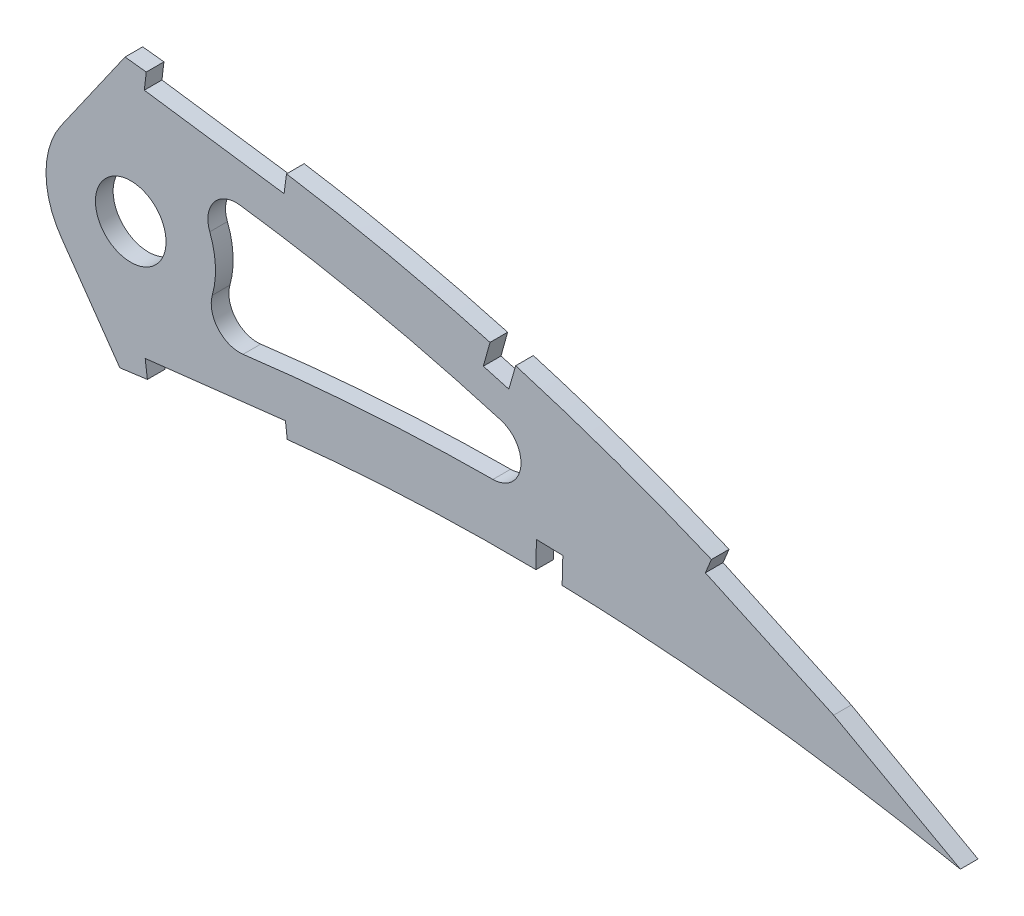
from build123d import *

# Parameters (mm, degrees)
BOSS_EXTRUDE1_DEPTH     = 3.175
SKETCH3_R               = 6.35
CUT_EXTRUDE2_DEPTH      = 7.62
CUT_EXTRUDE3_DEPTH      = 460.680430564
CUT_EXTRUDE3_DEPTH_BACK = 460.680430564
CUT_EXTRUDE4_DEPTH      = 459.987889409
FILLET1_R               = 5.08


with BuildPart() as part:
    # Sketch1 → Boss-Extrude1 (new body)
    with BuildSketch(Plane.XY):
        with BuildLine():
            Line((452.103130844, 0.704841059), (456.093968789, -1.676407199))
            Line((456.093968789, -1.676407199), (451.539257956, -0.704841059))
            add(Edge.make_bspline(
                [(0, 0), (0.116098484, -0.548062271), (0.348829019, -1.646705608), (0.981127511, -3.228296827), (1.817312083, -4.748664111), (2.874932324, -6.203769023), (4.146956076, -7.593213852), (5.630573928, -8.918443806), (7.324330898, -10.17874635), (9.226010202, -11.373547856), (11.332849305, -12.504116729), (13.642480166, -13.569749989), (16.152796843, -14.570114683), (18.861064307, -15.503873502), (21.763971588, -16.372448625), (24.858758771, -17.173723352), (28.141906776, -17.908817596), (31.610257831, -18.575854993), (35.260032504, -19.175513209), (39.087439203, -19.707456616), (43.088549366, -20.172017908), (47.259437594, -20.568222339), (51.595978462, -20.896922095), (56.093849686, -21.158335191), (60.748685259, -21.353290574), (65.556026339, -21.481047186), (70.511164689, -21.543596642), (75.60962225, -21.541878079), (80.846411515, -21.475431763), (86.217059019, -21.347928406), (91.716411041, -21.158560481), (97.339502767, -20.909619435), (103.081262098, -20.60361064), (108.936539298, -20.241571378), (114.900181528, -19.825106256), (120.967010704, -19.35755507), (127.131515672, -18.84008407), (133.388320155, -18.27570942), (139.73188498, -17.667256592), (146.156729407, -17.016651105), (152.657182369, -16.326953548), (159.227454029, -15.600398833), (165.861955098, -14.840863119), (172.554624992, -14.049720613), (179.299804335, -13.231488425), (186.0911476, -12.387729793), (192.922975871, -11.521694689), (199.789144556, -10.637460813), (206.683225759, -9.734927313), (213.599421065, -8.820524357), (220.53106073, -7.893498895), (227.472111233, -6.958618548), (234.416147314, -6.018789286), (241.356405409, -5.07430035), (248.28678484, -4.129065861), (255.200856388, -3.185680808), (262.091847615, -2.244231265), (268.953524037, -1.309396646), (275.778976202, -0.38106275), (282.561910312, 0.538888344), (289.295826346, 1.447710664), (295.974371147, 2.344257157), (302.590655451, 3.227960607), (309.138022785, 4.099152889), (315.511866205, 4.931391047), (321.69553077, 5.768992271), (327.709854245, 6.4556395), (333.649291775, 7.04171769), (339.520012945, 7.522220911), (345.31496828, 7.904062197), (351.027518107, 8.189969928), (356.650854245, 8.383935735), (362.17787359, 8.491713952), (367.601672755, 8.516039607), (372.914848341, 8.464670411), (378.110490176, 8.34174704), (383.181346836, 8.152787103), (388.120344083, 7.904165623), (392.920466429, 7.60266025), (397.574507523, 7.252718477), (402.075982121, 6.8625098), (406.417945063, 6.437746476), (410.593729281, 5.983281443), (414.597241701, 5.508637621), (418.422074216, 5.016940024), (422.062473684, 4.516268978), (425.512580015, 4.011698392), (428.766929364, 3.509669922), (431.820408455, 3.014973074), (434.668085107, 2.534173613), (437.305498365, 2.071763811), (439.728071725, 1.632259415), (441.932444373, 1.221205742), (443.914262697, 0.840644737), (445.670876088, 0.49684807), (447.199018295, 0.19133282), (448.496449148, -0.071596745), (449.560902928, -0.290902855), (450.390762879, -0.462985534), (450.984389878, -0.5881196), (451.34114184, -0.662580877), (451.499651332, -0.696392563), (451.539257956, -0.704841059)],
                knots=[0, 0, 0, 0, 0.003638255, 0.007293231, 0.011028136, 0.014901081, 0.018963272, 0.023258475, 0.027820626, 0.032679082, 0.03785316, 0.043361875, 0.049214679, 0.055422346, 0.061988786, 0.068918036, 0.076211157, 0.083868392, 0.091887411, 0.100265912, 0.108999867, 0.118084529, 0.127514843, 0.13728527, 0.147387917, 0.157816481, 0.168563473, 0.179619128, 0.190977373, 0.202626974, 0.214560478, 0.226767249, 0.239236417, 0.251959004, 0.264923894, 0.278119703, 0.291536035, 0.30516028, 0.318980685, 0.332985499, 0.34716279, 0.361498603, 0.375980747, 0.390597192, 0.405332593, 0.420174823, 0.435109533, 0.450124276, 0.465203068, 0.480333154, 0.495500583, 0.510689775, 0.525887334, 0.541078314, 0.556247233, 0.571381785, 0.58646604, 0.601484515, 0.616424329, 0.631269423, 0.646006524, 0.660620684, 0.675098187, 0.689422858, 0.703581825, 0.716907563, 0.730009274, 0.742952128, 0.755725557, 0.768319951, 0.780724337, 0.792926528, 0.804916041, 0.816679084, 0.828203525, 0.8394749, 0.850481359, 0.861207697, 0.871639326, 0.881763414, 0.891563605, 0.901027365, 0.910138977, 0.918883977, 0.927249278, 0.935221104, 0.942784739, 0.949928188, 0.956638465, 0.962904203, 0.968712288, 0.974054485, 0.978918432, 0.983297219, 0.987180246, 0.990560674, 0.993433357, 0.995790626, 0.997629588, 0.998945816, 0.999736592, 1, 1, 1, 1], degree=3))
            add(Edge.make_bspline(
                [(452.103130844, 0.704841059), (452.068496813, 0.726236426), (451.930095213, 0.811734792), (451.618251437, 1.003015711), (451.098966561, 1.321603382), (450.372013154, 1.765285304), (449.437955605, 2.332883088), (448.296324058, 3.020422222), (446.947831268, 3.825669225), (445.392803438, 4.744815234), (443.631400049, 5.773556989), (441.66429165, 6.907726386), (439.491649667, 8.140902925), (437.114315549, 9.468047233), (434.533105048, 10.882848063), (431.748506266, 12.378914822), (428.761516485, 13.948638114), (425.573282246, 15.58526602), (422.184384898, 17.279761053), (418.59642206, 19.025070833), (414.810589229, 20.812493246), (410.828178709, 22.632492429), (406.65147817, 24.477648573), (402.281642423, 26.336490908), (397.721161703, 28.200965635), (392.971977542, 30.06046153), (388.036901986, 31.906510246), (382.917838926, 33.727152381), (377.618614974, 35.514431666), (372.141800823, 37.256737501), (366.491313143, 38.944607324), (360.670434952, 40.56709799), (354.684018662, 42.115888344), (348.535860801, 43.579699531), (342.231172339, 44.948733274), (335.774964791, 46.214747245), (329.172652762, 47.36510198), (322.442531978, 48.398900537), (315.692888447, 49.25884604), (308.957131835, 50.102255317), (302.231406377, 50.894561333), (295.423478513, 51.653303868), (288.539897863, 52.374211064), (281.587492313, 53.055028822), (274.573300246, 53.692818583), (267.504610588, 54.285710178), (260.388263375, 54.830343915), (253.231762389, 55.325880728), (246.04218283, 55.767964282), (238.827182474, 56.156262652), (231.594085468, 56.488067665), (224.350419046, 56.761093174), (217.103874943, 56.973690929), (209.861975326, 57.123824182), (202.632561324, 57.210549036), (195.423152651, 57.231495803), (188.241586793, 57.186289729), (181.095384018, 57.073378669), (173.992389816, 56.89121691), (166.940134698, 56.63946441), (159.9462446, 56.318230463), (153.018377106, 55.924824851), (146.164047723, 55.461754745), (139.39088931, 54.92707481), (132.706343647, 54.320642895), (126.117416199, 53.644986873), (119.631442696, 52.898268934), (113.255374135, 52.082613865), (106.996184656, 51.199620764), (100.86089724, 50.248808671), (94.856084142, 49.232924024), (88.98822628, 48.153006108), (83.263531815, 47.012221039), (77.688233433, 45.810866329), (72.268232878, 44.552545746), (67.009162956, 43.23945158), (61.916677035, 41.873987713), (56.99593741, 40.459430694), (52.251920045, 38.998989643), (47.690155321, 37.494269359), (43.314090924, 35.950975056), (39.129102409, 34.370202293), (35.138395613, 32.756820932), (31.346647327, 31.113033952), (27.756690145, 29.443852436), (24.372587071, 27.751176724), (21.196749975, 26.039749097), (18.232367129, 24.312193837), (15.482292083, 22.571719722), (12.9476807, 20.82274152), (10.632027491, 19.066357057), (8.536127933, 17.307004609), (6.661308341, 15.547363257), (5.010248609, 13.788645116), (3.582889331, 12.033947283), (2.381101114, 10.284659424), (1.405092396, 8.542436815), (0.657070826, 6.808544998), (0.13629461, 5.083959089), (-0.148774805, 3.371224525), (-0.21973029, 1.668968236), (-0.073133992, 0.555491501), (0, 0)],
                knots=[0, 0, 0, 0, 0.00025409, 0.001015373, 0.002283359, 0.004056577, 0.006330982, 0.009105274, 0.012374489, 0.016134023, 0.02037966, 0.025105976, 0.030306237, 0.035972206, 0.042099522, 0.048678064, 0.055701664, 0.063160184, 0.071045824, 0.079349826, 0.08806291, 0.097175756, 0.106678112, 0.116561573, 0.126814275, 0.137428301, 0.148393618, 0.15969976, 0.171338126, 0.183297699, 0.195569604, 0.208143556, 0.221011593, 0.234161831, 0.24758745, 0.261276822, 0.27522271, 0.289414144, 0.303771199, 0.317689227, 0.331784111, 0.346039677, 0.36044387, 0.37498272, 0.389640454, 0.404403316, 0.419256601, 0.434186749, 0.449177265, 0.464214782, 0.479284009, 0.49436974, 0.509457833, 0.524532346, 0.53957932, 0.554582984, 0.569529546, 0.584403417, 0.599190992, 0.613876838, 0.628447475, 0.642888675, 0.657186054, 0.671325546, 0.685294014, 0.699078147, 0.712665095, 0.726042645, 0.739197713, 0.752117586, 0.764792042, 0.777208152, 0.789355685, 0.80122396, 0.812803686, 0.824082909, 0.835054602, 0.845709571, 0.856037853, 0.866033834, 0.875688843, 0.884997719, 0.893953426, 0.902552897, 0.910789386, 0.918660734, 0.926166253, 0.933302626, 0.94007122, 0.94647478, 0.952517526, 0.958204819, 0.963546652, 0.9685566, 0.973249913, 0.977651041, 0.981787043, 0.985694226, 0.989415109, 0.993001157, 0.996508416, 1, 1, 1, 1], degree=3))
        make_face()
    extrude(amount=BOSS_EXTRUDE1_DEPTH)

    # Sketch3 → Cut-Extrude2 (cut)
    with BuildSketch(Plane(origin=(0, 0, 0), x_dir=(-1, 0, 0), z_dir=(0, 0, -1))):
        with Locations((-299.038447077, 26.255421435)):
            Circle(SKETCH3_R)
    extrude(amount=-CUT_EXTRUDE2_DEPTH, mode=Mode.SUBTRACT)

    # Sketch4 → Cut-Extrude3 (cut, two sides)
    with BuildSketch(Plane.XY.offset(3.175)) as cut_extrude3_sk:
        with BuildLine():
            ThreePointArc((286.554569922, 17.514116545), (283.798447077, 26.255421435), (286.554569922, 34.996726325))
            Line((286.554569922, 34.996726325), (291.360999499, 41.861019145))
            Line((291.360999499, 41.861019145), (298.013920258, 51.362374666))
            add(Edge.make_bspline(
                [(298.013920258, 51.362374666), (297.158172729, 51.45702442), (294.008181803, 51.801525794), (288.539897863, 52.374211064), (281.587492313, 53.055028822), (274.573300246, 53.692818583), (267.504610588, 54.285710178), (260.388263375, 54.830343915), (253.231762389, 55.325880728), (246.04218283, 55.767964282), (238.827182474, 56.156262652), (231.594085468, 56.488067665), (224.350419046, 56.761093174), (217.103874943, 56.973690929), (209.861975326, 57.123824182), (202.632561324, 57.210549036), (195.423152651, 57.231495803), (188.241586793, 57.186289729), (181.095384018, 57.073378669), (173.992389816, 56.89121691), (166.940134698, 56.63946441), (159.9462446, 56.318230463), (154.912407449, 56.032379184), (152.210390737, 55.861831716), (151.817548324, 55.836670076)],
                knots=[0.340665949, 0.340665949, 0.340665949, 0.340665949, 0.346039677, 0.36044387, 0.37498272, 0.389640454, 0.404403316, 0.419256601, 0.434186749, 0.449177265, 0.464214782, 0.479284009, 0.49436974, 0.509457833, 0.524532346, 0.53957932, 0.554582984, 0.569529546, 0.584403417, 0.599190992, 0.613876838, 0.628447475, 0.642888675, 0.645345618, 0.645345618, 0.645345618, 0.645345618], degree=3))
            add(Edge.make_bspline(
                [(151.817548324, 55.836670076), (149.924372746, 55.715411774), (145.771614423, 55.430775666), (139.39088931, 54.92707481), (132.706343647, 54.320642895), (126.117416199, 53.644986873), (119.631442696, 52.898268934), (113.255374135, 52.082613865), (106.996184656, 51.199620764), (100.86089724, 50.248808671), (94.856084142, 49.232924024), (88.98822628, 48.153006108), (83.263531815, 47.012221039), (77.688233433, 45.810866329), (72.268232878, 44.552545746), (67.009162956, 43.23945158), (61.916677035, 41.873987713), (56.99593741, 40.459430694), (52.251920045, 38.998989643), (47.690155321, 37.494269359), (43.314090924, 35.950975056), (39.129102409, 34.370202293), (35.138395613, 32.756820932), (31.346647327, 31.113033952), (27.756690145, 29.443852436), (24.372587071, 27.751176724), (21.196749975, 26.039749097), (18.232367129, 24.312193837), (15.482292083, 22.571719722), (12.9476807, 20.82274152), (10.632027491, 19.066357057), (8.536127933, 17.307004609), (6.661308341, 15.547363257), (5.010248609, 13.788645116), (3.582889331, 12.033947283), (2.381101114, 10.284659424), (1.405092396, 8.542436815), (0.657070826, 6.808544998), (0.13629461, 5.083959089), (-0.148774805, 3.371224525), (-0.21973029, 1.668968236), (-0.073133992, 0.555491501), (0, 0)],
                knots=[0.645345618, 0.645345618, 0.645345618, 0.645345618, 0.657186054, 0.671325546, 0.685294014, 0.699078147, 0.712665095, 0.726042645, 0.739197713, 0.752117586, 0.764792042, 0.777208152, 0.789355685, 0.80122396, 0.812803686, 0.824082909, 0.835054602, 0.845709571, 0.856037853, 0.866033834, 0.875688843, 0.884997719, 0.893953426, 0.902552897, 0.910789386, 0.918660734, 0.926166253, 0.933302626, 0.94007122, 0.94647478, 0.952517526, 0.958204819, 0.963546652, 0.9685566, 0.973249913, 0.977651041, 0.981787043, 0.985694226, 0.989415109, 0.993001157, 0.996508416, 1, 1, 1, 1], degree=3))
            add(Edge.make_bspline(
                [(0, 0), (0.116098484, -0.548062271), (0.348829019, -1.646705608), (0.981127511, -3.228296827), (1.817312083, -4.748664111), (2.874932324, -6.203769023), (4.146956076, -7.593213852), (5.630573928, -8.918443806), (7.324330898, -10.17874635), (9.226010202, -11.373547856), (11.332849305, -12.504116729), (13.642480166, -13.569749989), (16.152796843, -14.570114683), (18.861064307, -15.503873502), (21.763971588, -16.372448625), (24.858758771, -17.173723352), (28.141906776, -17.908817596), (31.610257831, -18.575854993), (35.260032504, -19.175513209), (39.087439203, -19.707456616), (43.088549366, -20.172017908), (47.259437594, -20.568222339), (51.595978462, -20.896922095), (56.093849686, -21.158335191), (60.748685259, -21.353290574), (65.556026339, -21.481047186), (70.511164689, -21.543596642), (75.60962225, -21.541878079), (80.846411515, -21.475431763), (86.217059019, -21.347928406), (91.716411041, -21.158560481), (97.339502767, -20.909619435), (103.081262098, -20.60361064), (108.936539298, -20.241571378), (114.900181528, -19.825106256), (120.967010704, -19.35755507), (127.131515672, -18.84008407), (133.388320155, -18.27570942), (139.73188498, -17.667256592), (146.156729407, -17.016651105), (152.657182369, -16.326953548), (159.227454029, -15.600398833), (164.423185784, -15.00557734), (167.428285856, -14.653970639), (168.221856304, -14.560625117)],
                knots=[0, 0, 0, 0, 0.003638255, 0.007293231, 0.011028136, 0.014901081, 0.018963272, 0.023258475, 0.027820626, 0.032679082, 0.03785316, 0.043361875, 0.049214679, 0.055422346, 0.061988786, 0.068918036, 0.076211157, 0.083868392, 0.091887411, 0.100265912, 0.108999867, 0.118084529, 0.127514843, 0.13728527, 0.147387917, 0.157816481, 0.168563473, 0.179619128, 0.190977373, 0.202626974, 0.214560478, 0.226767249, 0.239236417, 0.251959004, 0.264923894, 0.278119703, 0.291536035, 0.30516028, 0.318980685, 0.332985499, 0.34716279, 0.361498603, 0.375980747, 0.381177933, 0.381177933, 0.381177933, 0.381177933], degree=3))
            add(Edge.make_bspline(
                [(168.221856304, -14.560625117), (169.660104846, -14.391447873), (173.347852421, -13.953497195), (179.299804335, -13.231488425), (186.0911476, -12.387729793), (192.922975871, -11.521694689), (199.789144556, -10.637460813), (206.683225759, -9.734927313), (213.599421065, -8.820524357), (220.53106073, -7.893498895), (227.472111233, -6.958618548), (234.416147314, -6.018789286), (241.356405409, -5.07430035), (248.28678484, -4.129065861), (255.200856388, -3.185680808), (262.091847615, -2.244231265), (268.953524037, -1.309396646), (275.778976202, -0.38106275), (282.561910312, 0.538888344), (289.295826346, 1.447710664), (294.127893032, 2.096380782), (296.714481339, 2.44258854), (297.074078933, 2.490700718)],
                knots=[0.381177933, 0.381177933, 0.381177933, 0.381177933, 0.390597192, 0.405332593, 0.420174823, 0.435109533, 0.450124276, 0.465203068, 0.480333154, 0.495500583, 0.510689775, 0.525887334, 0.541078314, 0.556247233, 0.571381785, 0.58646604, 0.601484515, 0.616424329, 0.631269423, 0.646006524, 0.660620684, 0.662980449, 0.662980449, 0.662980449, 0.662980449], degree=3))
            Line((297.074078933, 2.490700718), (290.512280083, 11.861920667))
            Line((290.512280083, 11.861920667), (286.554569922, 17.514116545))
        make_face()
        with BuildLine():
            add(Edge.make_bspline(
                [(397.099522024, 17.473424975), (391.104870759, 19.944342333), (379.177241568, 24.454975752), (361.031599335, 30.108120681), (345.827122006, 33.867334113), (333.567983327, 36.314328103), (325.822177912, 37.620830237), (319.688308692, 38.50590344), (314.963719571, 39.109215878), (310.159271505, 39.713456799), (306.795732769, 40.122713606), (305.012513563, 40.334581661), (304.815814132, 40.357890364)],
                knots=[0.119621685, 0.119621685, 0.119621685, 0.119621685, 0.161336405, 0.201670506, 0.242004607, 0.262171657, 0.282338708, 0.292422233, 0.302505759, 0.312589284, 0.322672809, 0.323922714, 0.323922714, 0.323922714, 0.323922714], degree=3))
            ThreePointArc((304.815814132, 40.357890364), (311.693577932, 34.746903228), (314.278447077, 26.255421435))
            ThreePointArc((314.278447077, 26.255421435), (312.737622507, 19.577832608), (308.426715772, 14.250505321))
            add(Edge.make_bspline(
                [(308.426715772, 14.250505321), (309.883764278, 14.442106028), (312.813862177, 14.824905538), (317.172571012, 15.411601995), (321.750889037, 16.002865885), (327.831130307, 16.688761643), (335.429886376, 17.415497246), (347.62570179, 18.27521734), (362.899139077, 18.793639217), (380.425060388, 18.544010551), (391.813646799, 17.883889315), (397.099522024, 17.473424975)],
                knots=[0.690710776, 0.690710776, 0.690710776, 0.690710776, 0.700258061, 0.709927156, 0.719596251, 0.729265346, 0.748603535, 0.767941725, 0.806618104, 0.845294483, 0.878913441, 0.878913441, 0.878913441, 0.878913441], degree=3))
        make_face()
    extrude(amount=CUT_EXTRUDE3_DEPTH, mode=Mode.SUBTRACT)
    extrude(cut_extrude3_sk.sketch, amount=-CUT_EXTRUDE3_DEPTH_BACK, mode=Mode.SUBTRACT)

    # Sketch5 → Cut-Extrude4 (cut, through all)
    with BuildSketch(Plane.XY.offset(3.175)):
        with BuildLine():
            add(Edge.make_bspline(
                [(307.959300125, 50.214688749), (306.058923831, 50.443506309), (304.01571842, 50.683216606), (301.971854133, 50.917122235), (301.829686497, 50.933363768)],
                knots=[0.319837191, 0.319837191, 0.319837191, 0.319837191, 0.331784111, 0.332677221, 0.332677221, 0.332677221, 0.332677221], degree=3))
            Line((301.829686497, 50.933363768), (301.47482345, 47.924910023))
            Line((301.47482345, 47.924910023), (326.610444398, 44.375507873))
            Line((326.610444398, 44.375507873), (327.027010314, 47.522970534))
            Line((327.027010314, 47.522970534), (307.959300125, 50.214688749))
        make_face()
        with BuildLine():
            add(Edge.make_bspline(
                [(327.049592603, 47.682939934), (325.523118102, 47.922682111), (321.719757816, 48.490986347), (315.692888447, 49.25884604), (310.85639105, 49.864441967), (308.300973051, 50.173549126), (307.959300125, 50.214688749)],
                knots=[0.279770165, 0.279770165, 0.279770165, 0.279770165, 0.289414144, 0.303771199, 0.317689227, 0.319837191, 0.319837191, 0.319837191, 0.319837191], degree=3))
            Line((307.959300125, 50.214688749), (327.027010314, 47.522970534))
            Line((327.027010314, 47.522970534), (327.049592603, 47.682939934))
        make_face()
        with BuildLine():
            Line((367.027712556, 34.144621107), (368.258765586, 38.409847596))
            add(Edge.make_bspline(
                [(368.258765586, 38.409847596), (367.683881505, 38.57934129), (366.146716026, 39.027931219), (364.606254541, 39.465110892), (363.641136877, 39.734202803)],
                knots=[0.191828805, 0.191828805, 0.191828805, 0.191828805, 0.195569604, 0.201823073, 0.201823073, 0.201823073, 0.201823073], degree=3))
            Line((363.641136877, 39.734202803), (362.440286106, 35.422164031))
            Line((362.440286106, 35.422164031), (367.027712556, 34.144621107))
        make_face()
        with BuildLine():
            add(Edge.make_bspline(
                [(368.258765586, 38.409847596), (367.683881505, 38.57934129), (366.146716026, 39.027931219), (364.606254541, 39.465110892), (363.641136877, 39.734202803)],
                knots=[0.191828805, 0.191828805, 0.191828805, 0.191828805, 0.195569604, 0.201823073, 0.201823073, 0.201823073, 0.201823073], degree=3))
            Line((368.258765586, 38.409847596), (368.338561592, 38.686316626))
            Line((368.338561592, 38.686316626), (363.717829024, 40.009590483))
            Line((363.717829024, 40.009590483), (363.641136877, 39.734202803))
        make_face()
        with BuildLine():
            Line((425.430642214, 12.576588432), (447.661879929, 0.292432154))
            Line((447.661879929, 0.292432154), (448.951197548, 2.625773233))
            add(Edge.make_bspline(
                [(448.951197548, 2.625773233), (448.755531686, 2.743656873), (448.110822834, 3.131193526), (446.947831268, 3.825669225), (445.392803438, 4.744815234), (443.631400049, 5.773556989), (441.66429165, 6.907726386), (439.491649667, 8.140902925), (437.114315549, 9.468047233), (434.533105048, 10.882848063), (431.748506266, 12.378914822), (428.761516485, 13.948638114), (425.573282246, 15.58526602), (422.184384898, 17.279761053), (418.59642206, 19.025070833), (414.810589229, 20.812493246), (410.828178709, 22.632492429), (407.023956095, 24.313097649), (404.542412985, 25.374002974), (403.458420651, 25.830826449)],
                knots=[0.007679507, 0.007679507, 0.007679507, 0.007679507, 0.009105274, 0.012374489, 0.016134023, 0.02037966, 0.025105976, 0.030306237, 0.035972206, 0.042099522, 0.048678064, 0.055701664, 0.063160184, 0.071045824, 0.079349826, 0.08806291, 0.097175756, 0.106678112, 0.114020064, 0.114020064, 0.114020064, 0.114020064], degree=3))
            Line((403.458420651, 25.830826449), (402.367162905, 23.210109258))
            Line((402.367162905, 23.210109258), (425.430642214, 12.576588432))
        make_face()
        with BuildLine():
            add(Edge.make_bspline(
                [(448.951197548, 2.625773233), (448.755531686, 2.743656873), (448.110822834, 3.131193526), (446.947831268, 3.825669225), (445.392803438, 4.744815234), (443.631400049, 5.773556989), (441.66429165, 6.907726386), (439.491649667, 8.140902925), (437.114315549, 9.468047233), (434.533105048, 10.882848063), (431.748506266, 12.378914822), (428.761516485, 13.948638114), (425.573282246, 15.58526602), (422.184384898, 17.279761053), (418.59642206, 19.025070833), (414.810589229, 20.812493246), (410.828178709, 22.632492429), (407.023956095, 24.313097649), (404.542412985, 25.374002974), (403.458420651, 25.830826449)],
                knots=[0.007679507, 0.007679507, 0.007679507, 0.007679507, 0.009105274, 0.012374489, 0.016134023, 0.02037966, 0.025105976, 0.030306237, 0.035972206, 0.042099522, 0.048678064, 0.055701664, 0.063160184, 0.071045824, 0.079349826, 0.08806291, 0.097175756, 0.106678112, 0.114020064, 0.114020064, 0.114020064, 0.114020064], degree=3))
            Line((448.951197548, 2.625773233), (449.197399463, 3.071336867))
            Line((449.197399463, 3.071336867), (426.966161748, 15.355493146))
            Line((426.966161748, 15.355493146), (426.650861301, 15.507013585))
            Line((426.650861301, 15.507013585), (403.587381995, 26.140534411))
            Line((403.587381995, 26.140534411), (403.458420651, 25.830826449))
        make_face()
        with BuildLine():
            add(Edge.make_bspline(
                [(448.219794673, -0.015850812), (448.337859302, -0.039881676), (448.811017615, -0.13640631), (449.560902928, -0.290902855), (450.390762879, -0.462985534), (450.984389878, -0.5881196), (451.34114184, -0.662580877), (451.499651332, -0.696392563), (451.539257956, -0.704841059)],
                knots=[0.992649687, 0.992649687, 0.992649687, 0.992649687, 0.993433357, 0.995790626, 0.997629588, 0.998945816, 0.999736592, 1, 1, 1, 1], degree=3))
            Line((448.219794673, -0.015850812), (455.663449436, -4.128937972))
            Line((455.663449436, -4.128937972), (457.19896897, -1.350033259))
            Line((457.19896897, -1.350033259), (449.197399463, 3.071336867))
            Line((449.197399463, 3.071336867), (448.951197548, 2.625773233))
            add(Edge.make_bspline(
                [(452.103130844, 0.704841059), (452.068496813, 0.726236426), (451.930095213, 0.811734792), (451.618251437, 1.003015711), (451.098966561, 1.321603382), (450.372013154, 1.765285304), (449.633171928, 2.214256187), (449.136262949, 2.514276098), (448.951197548, 2.625773233)],
                knots=[0, 0, 0, 0, 0.00025409, 0.001015373, 0.002283359, 0.004056577, 0.006330982, 0.007679507, 0.007679507, 0.007679507, 0.007679507], degree=3))
            Line((452.103130844, 0.704841059), (456.093968789, -1.676407199))
            Line((456.093968789, -1.676407199), (451.539257956, -0.704841059))
        make_face()
        with BuildLine():
            Line((447.661879929, 0.292432154), (448.219794673, -0.015850812))
            add(Edge.make_bspline(
                [(448.219794673, -0.015850812), (448.337859302, -0.039881676), (448.811017615, -0.13640631), (449.560902928, -0.290902855), (450.390762879, -0.462985534), (450.984389878, -0.5881196), (451.34114184, -0.662580877), (451.499651332, -0.696392563), (451.539257956, -0.704841059)],
                knots=[0.992649687, 0.992649687, 0.992649687, 0.992649687, 0.993433357, 0.995790626, 0.997629588, 0.998945816, 0.999736592, 1, 1, 1, 1], degree=3))
            Line((451.539257956, -0.704841059), (456.093968789, -1.676407199))
            Line((456.093968789, -1.676407199), (452.103130844, 0.704841059))
            add(Edge.make_bspline(
                [(452.103130844, 0.704841059), (452.068496813, 0.726236426), (451.930095213, 0.811734792), (451.618251437, 1.003015711), (451.098966561, 1.321603382), (450.372013154, 1.765285304), (449.633171928, 2.214256187), (449.136262949, 2.514276098), (448.951197548, 2.625773233)],
                knots=[0, 0, 0, 0, 0.00025409, 0.001015373, 0.002283359, 0.004056577, 0.006330982, 0.007679507, 0.007679507, 0.007679507, 0.007679507], degree=3))
            Line((448.951197548, 2.625773233), (447.661879929, 0.292432154))
        make_face()
        with BuildLine():
            Line((371.976721083, 13.221010939), (371.910804417, 8.46777718))
            add(Edge.make_bspline(
                [(371.910804417, 8.46777718), (372.258392102, 8.462922138), (373.825770339, 8.438858489), (375.392984747, 8.404989851), (376.612497888, 8.372718231)],
                knots=[0.825942515, 0.825942515, 0.825942515, 0.825942515, 0.828203525, 0.836138291, 0.836138291, 0.836138291, 0.836138291], degree=3))
            Line((376.612497888, 8.372718231), (376.736806311, 13.095671175))
            Line((376.736806311, 13.095671175), (371.976721083, 13.221010939))
        make_face()
        with BuildLine():
            add(Edge.make_bspline(
                [(371.910804417, 8.46777718), (372.258392102, 8.462922138), (373.825770339, 8.438858489), (375.392984747, 8.404989851), (376.612497888, 8.372718231)],
                knots=[0.825942515, 0.825942515, 0.825942515, 0.825942515, 0.828203525, 0.836138291, 0.836138291, 0.836138291, 0.836138291], degree=3))
            Line((371.910804417, 8.46777718), (371.910691402, 8.45962764))
            Line((371.910691402, 8.45962764), (376.612300587, 8.365222))
            Line((376.612300587, 8.365222), (376.612497888, 8.372718231))
        make_face()
        with BuildLine():
            Line((327.174950672, 6.382908239), (326.857001329, 9.13788844))
            Line((326.857001329, 9.13788844), (301.631726564, 6.237117628))
            Line((301.631726564, 6.237117628), (302.02970168, 3.152611918))
            add(Edge.make_bspline(
                [(302.02970168, 3.152611918), (302.224474566, 3.178586157), (304.602276292, 3.495626748), (309.138022785, 4.099152889), (315.511866205, 4.931391047), (321.509234715, 5.743757752), (325.359106229, 6.187074289), (327.174950672, 6.382908239)],
                knots=[0.673820116, 0.673820116, 0.673820116, 0.673820116, 0.675098187, 0.689422858, 0.703581825, 0.716907563, 0.728786522, 0.728786522, 0.728786522, 0.728786522], degree=3))
        make_face()
    extrude(amount=-CUT_EXTRUDE4_DEPTH, mode=Mode.SUBTRACT)

    # Fillet1
    fillet1_edges = [part.edges().sort_by_distance(p)[0] for p in [
        (397.099522024, 17.473424975, 1.5875),
        (308.426715772, 14.250505321, 1.5875),
        (304.815814132, 40.357890364, 1.5875),
    ]]
    fillet(fillet1_edges, radius=FILLET1_R)


solid = part.part
